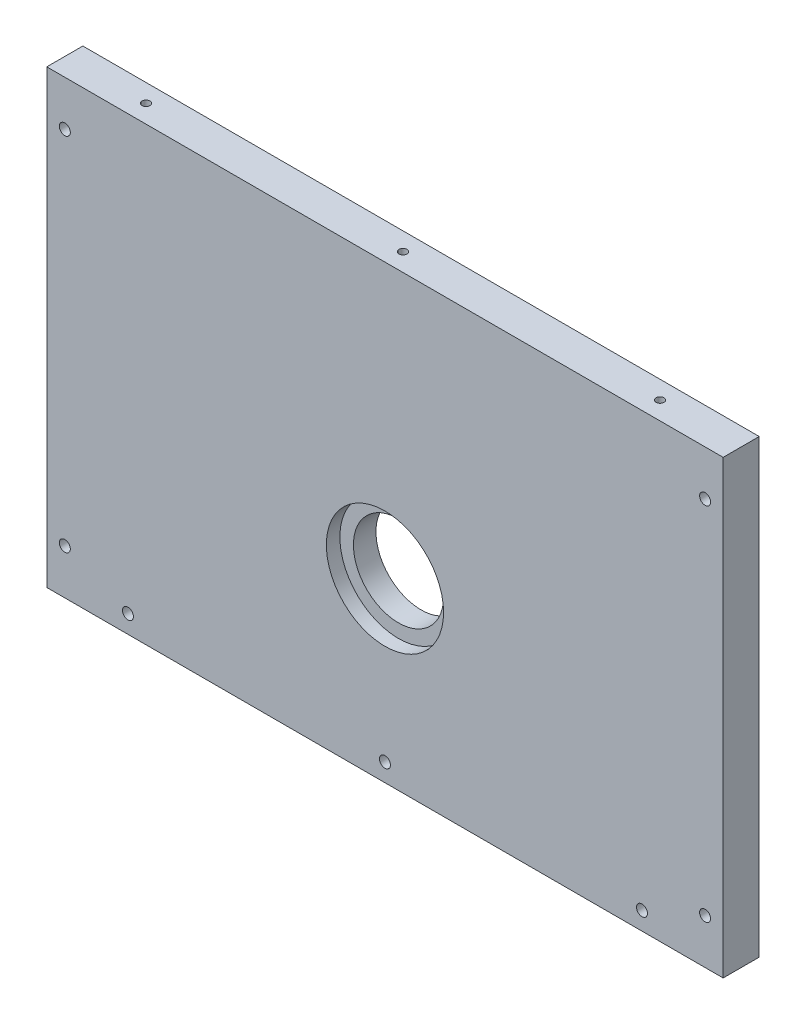
from build123d import *

# Parameters (mm, degrees)
SKETCH1_W                                      = 150
SKETCH1_H                                      = 100
BOSS_EXTRUDE1_DEPTH                            = 8
CBORE_FOR_2_SOCKET_HEAD_CAP_SCREW1_D           = 2.4384
CBORE_FOR_2_SOCKET_HEAD_CAP_SCREW1_CBORE_D     = 4.7625
CBORE_FOR_2_SOCKET_HEAD_CAP_SCREW1_CBORE_DEPTH = 2.1844
SKETCH5_R                                      = 10
CUT_EXTRUDE1_DEPTH                             = 9
SKETCH6_R                                      = 13
CUT_EXTRUDE2_DEPTH                             = 3
F_2_56_TAPPED_HOLE1_D                          = 1.778
F_2_56_TAPPED_HOLE1_DEPTH                      = 15
F_2_56_TAPPED_HOLE1_TIP                        = 0.53416509


with BuildPart() as part:
    # Sketch1 → Boss-Extrude1 (new body)
    with BuildSketch(Plane.XY):
        with Locations((75, 50)):
            Rectangle(SKETCH1_W, SKETCH1_H)
    extrude(amount=BOSS_EXTRUDE1_DEPTH)

    # CBORE for #2 Socket Head Cap Screw1 (through all)
    with Locations(Plane(origin=(0, 0, 0), x_dir=(-1, 0, 0), z_dir=(0, 0, -1))):
        with Locations((-132, 4), (-18, 4), (-4, 90), (-146, 90), (-146, 10), (-4, 10), (-75, 4)):
            CounterBoreHole(CBORE_FOR_2_SOCKET_HEAD_CAP_SCREW1_D / 2, CBORE_FOR_2_SOCKET_HEAD_CAP_SCREW1_CBORE_D / 2, CBORE_FOR_2_SOCKET_HEAD_CAP_SCREW1_CBORE_DEPTH)

    # Sketch5 → Cut-Extrude1 (cut, through all)
    with BuildSketch(Plane.XY.offset(8)):
        with Locations((75, 39.2)):
            Circle(SKETCH5_R)
    extrude(amount=-CUT_EXTRUDE1_DEPTH, mode=Mode.SUBTRACT)

    # Sketch6 → Cut-Extrude2 (cut)
    with BuildSketch(Plane.XY.offset(8)):
        with Locations((75, 39.2)):
            Circle(SKETCH6_R)
    extrude(amount=-CUT_EXTRUDE2_DEPTH, mode=Mode.SUBTRACT)

    # #2-56 Tapped Hole1
    with Locations(Plane(origin=(0, 100, 0), x_dir=(1, 0, 0), z_dir=(0, 1, 0))):
        with Locations((18, -4), (75, -4), (132, -4)):
            Hole(F_2_56_TAPPED_HOLE1_D / 2, depth=F_2_56_TAPPED_HOLE1_DEPTH)
            with Locations((0, 0, -(F_2_56_TAPPED_HOLE1_DEPTH + F_2_56_TAPPED_HOLE1_TIP / 2))):  # 118° drill point
                Cone(0, F_2_56_TAPPED_HOLE1_D / 2, F_2_56_TAPPED_HOLE1_TIP, mode=Mode.SUBTRACT)


solid = part.part
